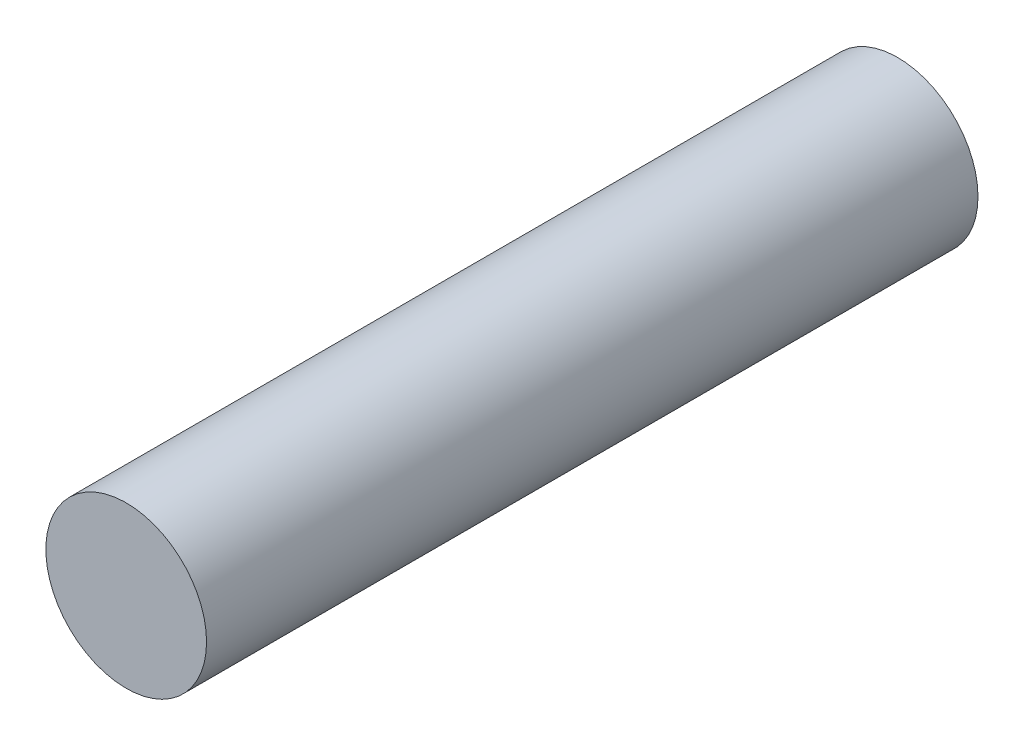
from build123d import *

# Parameters (mm, degrees)
SKETCH_1_R      = 2.5
EXTRUDE_1_DEPTH = 24


with BuildPart() as part:
    # 草图1 → 凸台-拉伸1 (new body)
    with BuildSketch(Plane.XY):
        Circle(SKETCH_1_R)
    extrude(amount=EXTRUDE_1_DEPTH)


solid = part.part
